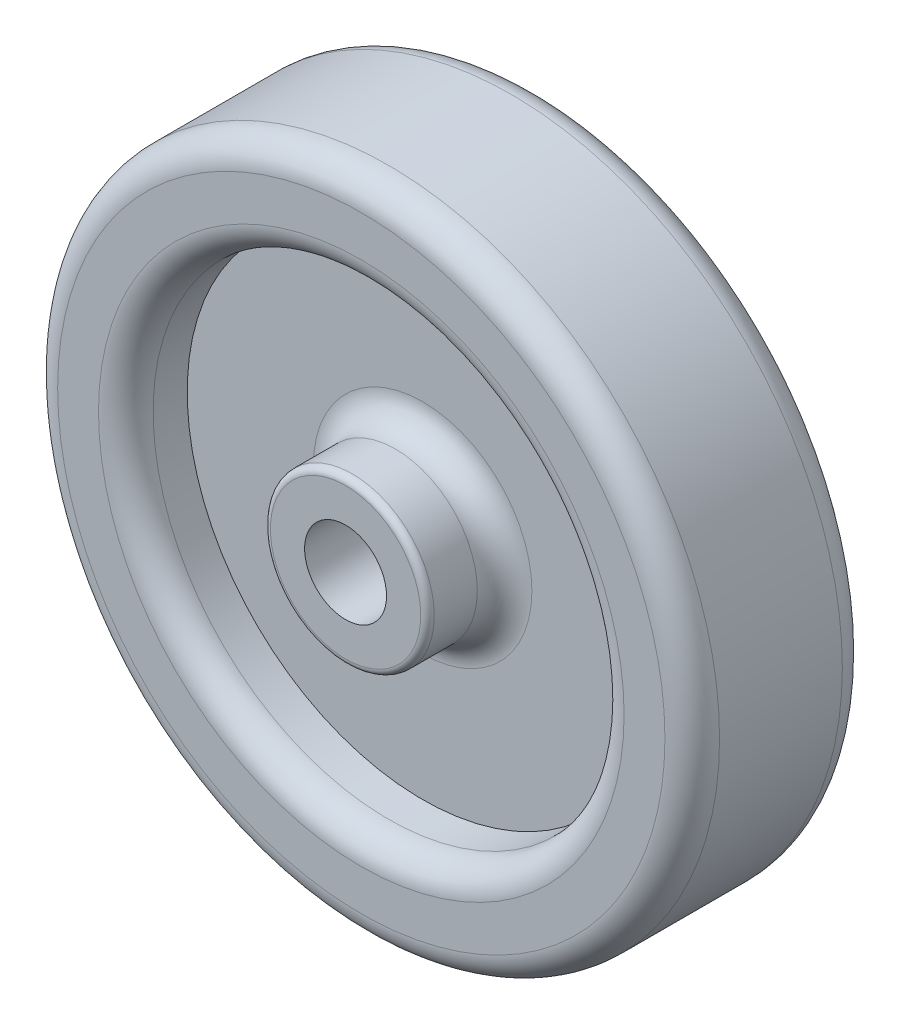
from build123d import *

# Parameters (mm, degrees)
SKETCH1_R                = 38.481
SKETCH1_R_2              = 4.7625
BOSS_EXTRUDE1_DEPTH      = 10.31494
BOSS_EXTRUDE1_DEPTH_BACK = 10.3124
SKETCH2_R                = 9.525
SKETCH2_R_2              = 4.7625
BOSS_EXTRUDE2_DEPTH      = 1.8288
BOSS_EXTRUDE2_DEPTH_BACK = 22.4536
SKETCH3_R                = 27.3812
SKETCH3_R_2              = 9.525
CUT_EXTRUDE1_DEPTH       = 7.1374
SKETCH4_R                = 27.3812
SKETCH4_R_2              = 9.525
CUT_EXTRUDE2_DEPTH       = 7.1374
FILLET1_R                = 3.175
FILLET2_R                = 0.7874


with BuildPart() as part:
    # Sketch1 → Boss-Extrude1 (new body, two sides)
    with BuildSketch(Plane.XY) as boss_extrude1_sk:
        Circle(SKETCH1_R)
        Circle(SKETCH1_R_2, mode=Mode.SUBTRACT)
    extrude(amount=BOSS_EXTRUDE1_DEPTH)
    extrude(boss_extrude1_sk.sketch, amount=-BOSS_EXTRUDE1_DEPTH_BACK)

    # Sketch2 → Boss-Extrude2 (add, two sides)
    with BuildSketch(Plane.XY.offset(10.31494)) as boss_extrude2_sk:
        Circle(SKETCH2_R)
        Circle(SKETCH2_R_2, mode=Mode.SUBTRACT)
    extrude(amount=BOSS_EXTRUDE2_DEPTH)
    extrude(boss_extrude2_sk.sketch, amount=-BOSS_EXTRUDE2_DEPTH_BACK)

    # Sketch3 → Cut-Extrude1 (cut)
    with BuildSketch(Plane(origin=(0, 0, -10.3124), x_dir=(-1, 0, 0), z_dir=(0, 0, -1))):
        Circle(SKETCH3_R)
        Circle(SKETCH3_R_2, mode=Mode.SUBTRACT)
    extrude(amount=-CUT_EXTRUDE1_DEPTH, mode=Mode.SUBTRACT)

    # Sketch4 → Cut-Extrude2 (cut)
    with BuildSketch(Plane.XY.offset(10.31494)):
        Circle(SKETCH4_R)
        Circle(SKETCH4_R_2, mode=Mode.SUBTRACT)
    extrude(amount=-CUT_EXTRUDE2_DEPTH, mode=Mode.SUBTRACT)

    # Fillet1
    fillet1_edges = [part.edges().sort_by_distance(p)[0] for p in [
        (9.525, 0, -3.175),
        (27.3812, 0, -10.3124),
        (-9.525, 0, 3.17754),
        (-27.3812, 0, 10.31494),
        (-38.481, 0, 10.31494),
        (-38.481, 0, -10.3124),
    ]]
    fillet(fillet1_edges, radius=FILLET1_R)

    # Fillet2
    fillet2_edges = [part.edges().sort_by_distance(p)[0] for p in [
        (-9.525, 0, -12.13866),
        (-9.525, 0, 12.14374),
    ]]
    fillet(fillet2_edges, radius=FILLET2_R)


solid = part.part
